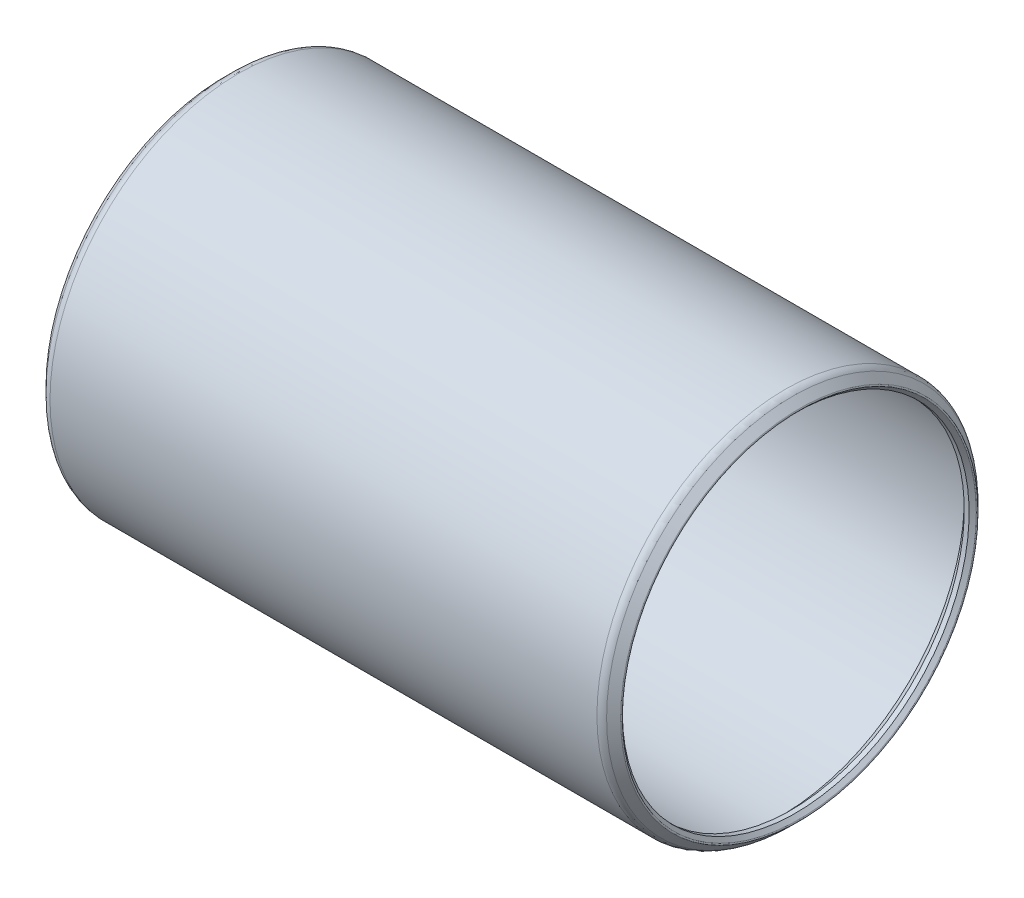
from build123d import *


with BuildPart() as part:
    # Sketch1 → Revolve1 (revolve)
    with BuildSketch(Plane.XY):
        with BuildLine():
            Line((-0.882617928, 18.554667928), (-0.508, 18.18005))
            Line((-0.508, 18.18005), (0, 18.18005))
            Line((0, 18.18005), (1.016, 19.19605))
            Line((1.016, 19.19605), (57.4675, 19.19605))
            Line((57.4675, 19.19605), (58.4835, 18.18005))
            Line((58.4835, 18.18005), (58.9915, 18.18005))
            Line((58.9915, 18.18005), (59.366117928, 18.554667928))
            ThreePointArc((59.366117928, 18.554667928), (59.403315367, 18.64447049), (59.366117928, 18.734273051))
            Line((59.366117928, 18.734273051), (58.63042049, 19.46997049))
            ThreePointArc((58.63042049, 19.46997049), (58.300806367, 19.690211605), (57.912, 19.76755))
            Line((57.912, 19.76755), (0.5715, 19.76755))
            ThreePointArc((0.5715, 19.76755), (0.182693633, 19.690211605), (-0.14692049, 19.46997049))
            Line((-0.14692049, 19.46997049), (-0.882617928, 18.734273051))
            ThreePointArc((-0.882617928, 18.734273051), (-0.919815367, 18.64447049), (-0.882617928, 18.554667928))
        make_face()
    revolve(axis=Axis((58.4835, 0, 0), (-1, 0, 0)))


solid = part.part
